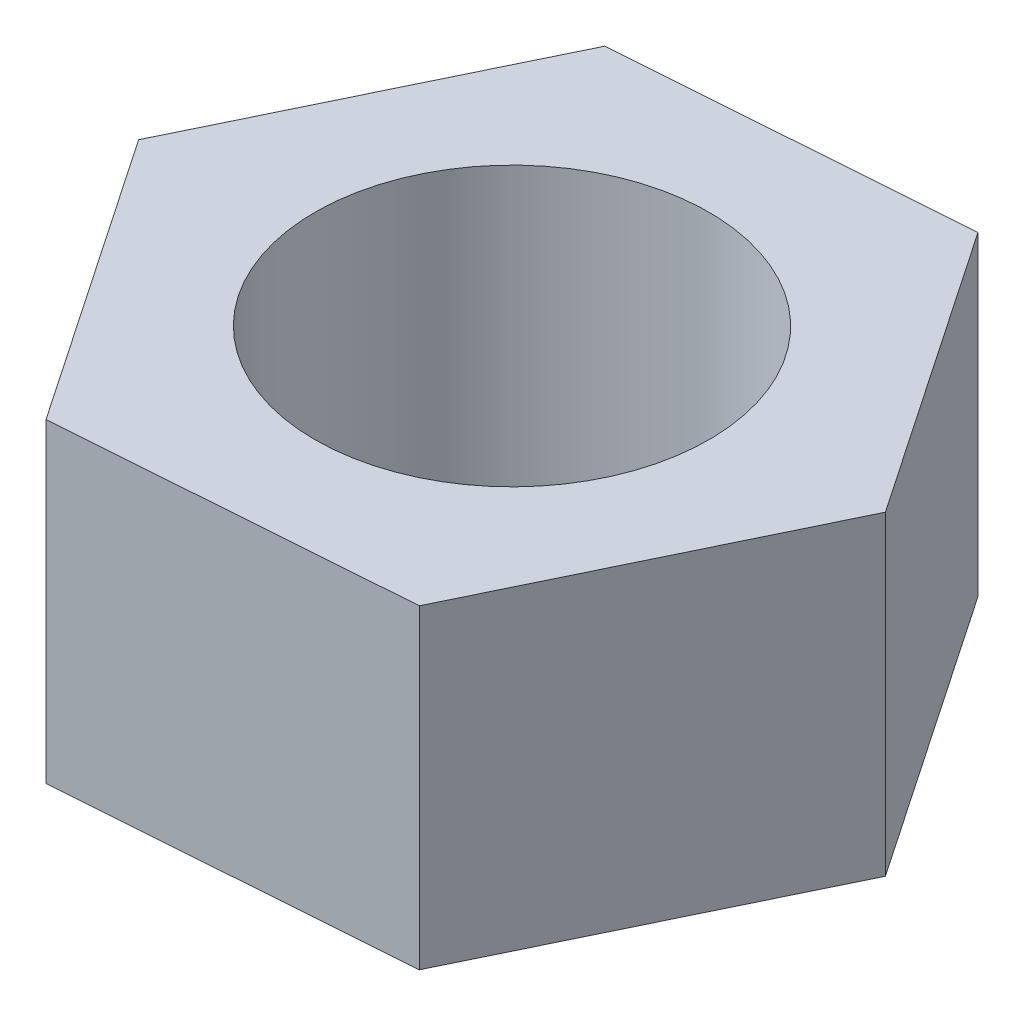
from build123d import *

# Parameters (mm, degrees)
BOSS_EXTRUDE1_DEPTH = 24
SKETCH2_R           = 15
CUT_EXTRUDE1_DEPTH  = 25


with BuildPart() as part:
    # Sketch1 → Boss-Extrude1 (new body)
    with BuildSketch(Plane(origin=(0, 0, 0), x_dir=(1, 0, 0), z_dir=(0, 1, 0))):
        Polygon((14.921035866, -21.970344149), (26.487394096, 1.936824036), (11.56635823, 23.907168185), (-14.921035866, 21.970344149), (-26.487394096, -1.936824036), (-11.56635823, -23.907168185), align=None)
    extrude(amount=BOSS_EXTRUDE1_DEPTH)

    # Sketch2 → Cut-Extrude1 (cut, through all)
    with BuildSketch(Plane(origin=(0, 24, 0), x_dir=(1, 0, 0), z_dir=(0, 1, 0))):
        Circle(SKETCH2_R)
    extrude(amount=-CUT_EXTRUDE1_DEPTH, mode=Mode.SUBTRACT)


solid = part.part
